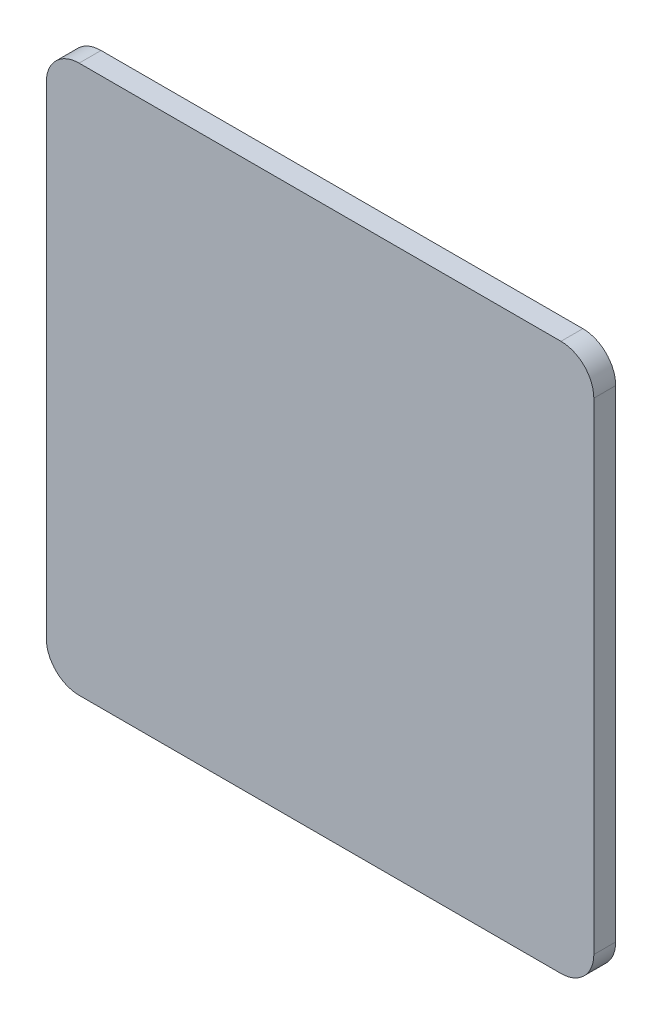
from build123d import *

# Parameters (mm, degrees)
SKETCH1_W           = 127
SKETCH1_H           = 127
BOSS_EXTRUDE1_DEPTH = 5.08
FILLET1_R           = 7.62


with BuildPart() as part:
    # Sketch1 → Boss-Extrude1 (new body)
    with BuildSketch(Plane.XY):
        Rectangle(SKETCH1_W, SKETCH1_H)
    extrude(amount=BOSS_EXTRUDE1_DEPTH)

    # Fillet1
    fillet1_edges = [part.edges().sort_by_distance(p)[0] for p in [
        (-63.5, 63.5, 2.54),
        (63.5, 63.5, 2.54),
        (63.5, -63.5, 2.54),
        (-63.5, -63.5, 2.54),
    ]]
    fillet(fillet1_edges, radius=FILLET1_R)


solid = part.part
